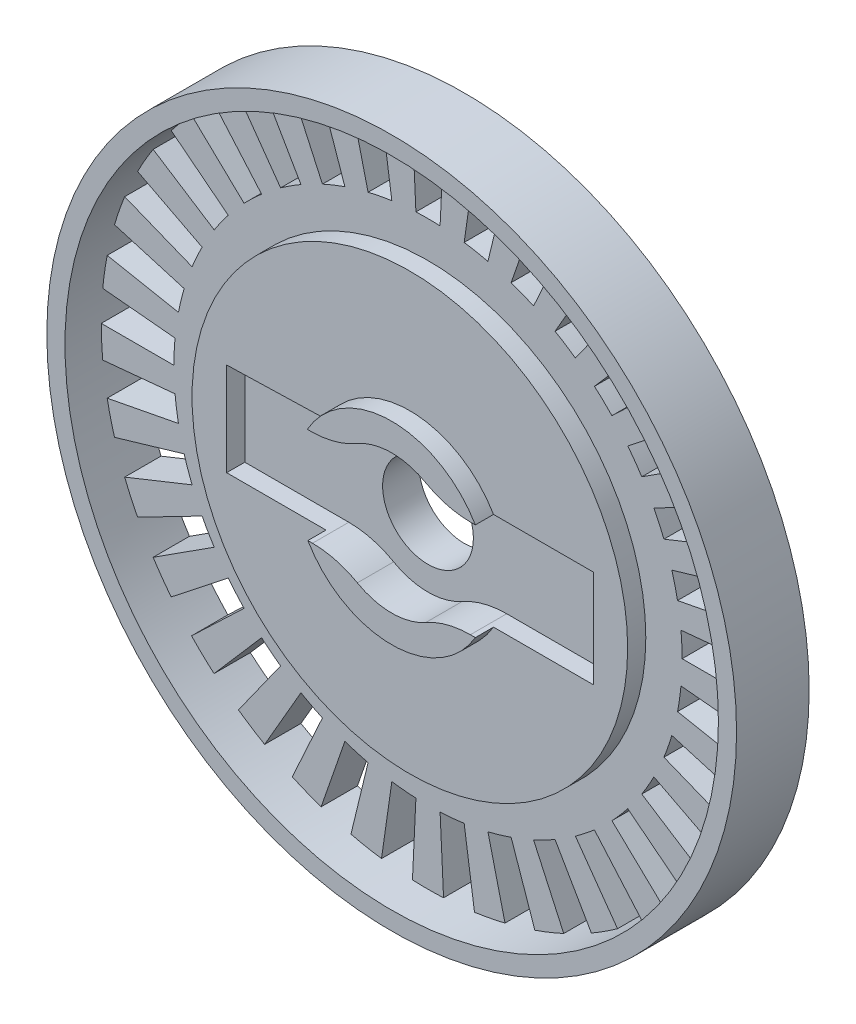
from build123d import *

# Parameters (mm, degrees)
SKETCH1_R           = 20
BOSS_EXTRUDE1_DEPTH = 4
SKETCH2_R           = 2.5
CUT_EXTRUDE1_DEPTH  = 4
CUT_EXTRUDE2_DEPTH  = 2
CUT_EXTRUDE3_DEPTH  = 4
SKETCH5_R           = 18
SKETCH5_R_2         = 12
CUT_EXTRUDE4_DEPTH  = 2
SKETCH6_R           = 13.335707923
SKETCH6_R_2         = 5.335707923
CUT_EXTRUDE5_DEPTH  = 1
FILLET2_R           = 5
SKETCH7_R           = 20
SKETCH7_R_2         = 19
CUT_EXTRUDE6_DEPTH  = 10


with BuildPart() as part:
    # Sketch1 → Boss-Extrude1 (new body)
    with BuildSketch(Plane.XY):
        Circle(SKETCH1_R)
    extrude(amount=BOSS_EXTRUDE1_DEPTH)

    # Sketch2 → Cut-Extrude1 (cut)
    with BuildSketch(Plane.XY.offset(4)):
        Circle(SKETCH2_R)
    extrude(amount=-CUT_EXTRUDE1_DEPTH, mode=Mode.SUBTRACT)

    # Sketch3 → Cut-Extrude2 (cut)
    with BuildSketch(Plane.XY.offset(4)):
        with BuildLine():
            Line((-2.737799224, -2.671157129), (-10.093588243, -2.671157129))
            Line((-10.093588243, -2.671157129), (-10.093588243, 2.468790745))
            Line((-10.093588243, 2.468790745), (-2.739511235, 2.66940128))
            ThreePointArc((-2.739511235, 2.66940128), (-0.013401979, 3.824976521), (2.720738068, 2.688532939))
            Line((2.720738068, 2.688532939), (10.108951703, 2.688532939))
            Line((10.108951703, 2.688532939), (10.108951703, 0.003240604))
            Line((10.108951703, 0.003240604), (10.108951703, -2.686788025))
            Line((10.108951703, -2.686788025), (2.722461223, -2.686788025))
            ThreePointArc((2.722461223, -2.686788025), (-0.010949648, -3.824984327), (-2.737799224, -2.671157129))
        make_face()
    extrude(amount=-CUT_EXTRUDE2_DEPTH, mode=Mode.SUBTRACT)

    # Sketch4 → Cut-Extrude3 (cut)
    with BuildSketch(Plane.XY.offset(4)):
        with BuildLine():
            Line((13.936606916, 1.330784606), (17.918494606, 1.711008779))
            ThreePointArc((17.918494606, 1.711008779), (17.979612105, 0.856474485), (18, 0))
            Line((18, 0), (14, 0))
            ThreePointArc((14, 0), (13.984142749, 0.666146822), (13.936606916, 1.330784606))
        make_face()
        with BuildLine():
            Line((13.936606916, -1.330784606), (17.918494606, -1.711008779))
            ThreePointArc((17.918494606, -1.711008779), (17.816785954, -2.561667089), (17.674716551, -3.406522398))
            Line((17.674716551, -3.406522398), (13.747001762, -2.649517421))
            ThreePointArc((13.747001762, -2.649517421), (13.857500186, -1.992407736), (13.936606916, -1.330784606))
        make_face()
        with BuildLine():
            Line((13.432901631, -3.944255796), (17.270873525, -5.071186023))
            ThreePointArc((17.270873525, -5.071186023), (17.010014737, -5.88722334), (16.710622794, -6.689924202))
            Line((16.710622794, -6.689924202), (12.997151062, -5.203274379))
            ThreePointArc((12.997151062, -5.203274379), (13.230011462, -4.578951486), (13.432901631, -3.944255796))
        make_face()
        with BuildLine():
            Line((12.443696281, -6.415171304), (15.999038076, -8.248077391))
            ThreePointArc((15.999038076, -8.248077391), (15.588457268, -9), (15.142563591, -9.731534714))
            Line((15.142563591, -9.731534714), (11.77754946, -7.568971444))
            ThreePointArc((11.77754946, -7.568971444), (12.124355653, -7), (12.443696281, -6.415171304))
        make_face()
        with BuildLine():
            Line((11.004743326, -8.654225807), (14.148955705, -11.126861752))
            ThreePointArc((14.148955705, -11.126861752), (13.603492338, -11.787493211), (13.027212686, -12.421422207))
            Line((13.027212686, -12.421422207), (10.132276533, -9.661106161))
            ThreePointArc((10.132276533, -9.661106161), (10.580494041, -9.168050275), (11.004743326, -8.654225807))
        make_face()
        with BuildLine():
            Line((9.168050275, -10.580494041), (11.787493211, -13.603492338))
            ThreePointArc((11.787493211, -13.603492338), (11.126861752, -14.148955705), (10.441024372, -14.662367137))
            Line((10.441024372, -14.662367137), (8.120796734, -11.404063329))
            ThreePointArc((8.120796734, -11.404063329), (8.654225807, -11.004743326), (9.168050275, -10.580494041))
        make_face()
        with BuildLine():
            Line((7, -12.124355653), (9, -15.588457268))
            ThreePointArc((9, -15.588457268), (8.248077391, -15.999038076), (7.477470234, -16.373375916))
            Line((7.477470234, -16.373375916), (5.815810182, -12.734847935))
            ThreePointArc((5.815810182, -12.734847935), (6.415171304, -12.443696281), (7, -12.124355653))
        make_face()
        with BuildLine():
            Line((4.578951486, -13.230011462), (5.88722334, -17.010014737))
            ThreePointArc((5.88722334, -17.010014737), (5.071186023, -17.270873525), (4.243660839, -17.49260823))
            Line((4.243660839, -17.49260823), (3.300625097, -13.605361957))
            ThreePointArc((3.300625097, -13.605361957), (3.944255796, -13.432901631), (4.578951486, -13.230011462))
        make_face()
        with BuildLine():
            Line((1.992407736, -13.857500186), (2.561667089, -17.816785954))
            ThreePointArc((2.561667089, -17.816785954), (1.711008779, -17.918494606), (0.856474485, -17.979612105))
            Line((0.856474485, -17.979612105), (0.666146822, -13.984142749))
            ThreePointArc((0.666146822, -13.984142749), (1.330784606, -13.936606916), (1.992407736, -13.857500186))
        make_face()
        with BuildLine():
            Line((-0.666146822, -13.984142749), (-0.856474485, -17.979612105))
            ThreePointArc((-0.856474485, -17.979612105), (-1.711008779, -17.918494606), (-2.561667089, -17.816785954))
            Line((-2.561667089, -17.816785954), (-1.992407736, -13.857500186))
            ThreePointArc((-1.992407736, -13.857500186), (-1.330784606, -13.936606916), (-0.666146822, -13.984142749))
        make_face()
        with BuildLine():
            Line((-3.300625097, -13.605361957), (-4.243660839, -17.49260823))
            ThreePointArc((-4.243660839, -17.49260823), (-5.071186023, -17.270873525), (-5.88722334, -17.010014737))
            Line((-5.88722334, -17.010014737), (-4.578951486, -13.230011462))
            ThreePointArc((-4.578951486, -13.230011462), (-3.944255796, -13.432901631), (-3.300625097, -13.605361957))
        make_face()
        with BuildLine():
            Line((-5.815810182, -12.734847935), (-7.477470234, -16.373375916))
            ThreePointArc((-7.477470234, -16.373375916), (-8.248077391, -15.999038076), (-9, -15.588457268))
            Line((-9, -15.588457268), (-7, -12.124355653))
            ThreePointArc((-7, -12.124355653), (-6.415171304, -12.443696281), (-5.815810182, -12.734847935))
        make_face()
        with BuildLine():
            Line((-8.120796734, -11.404063329), (-10.441024372, -14.662367137))
            ThreePointArc((-10.441024372, -14.662367137), (-11.126861752, -14.148955705), (-11.787493211, -13.603492338))
            Line((-11.787493211, -13.603492338), (-9.168050275, -10.580494041))
            ThreePointArc((-9.168050275, -10.580494041), (-8.654225807, -11.004743326), (-8.120796734, -11.404063329))
        make_face()
        with BuildLine():
            Line((-10.132276533, -9.661106161), (-13.027212686, -12.421422207))
            ThreePointArc((-13.027212686, -12.421422207), (-13.603492338, -11.787493211), (-14.148955705, -11.126861752))
            Line((-14.148955705, -11.126861752), (-11.004743326, -8.654225807))
            ThreePointArc((-11.004743326, -8.654225807), (-10.580494041, -9.168050275), (-10.132276533, -9.661106161))
        make_face()
        with BuildLine():
            Line((-11.77754946, -7.568971444), (-15.142563591, -9.731534714))
            ThreePointArc((-15.142563591, -9.731534714), (-15.588457268, -9), (-15.999038076, -8.248077391))
            Line((-15.999038076, -8.248077391), (-12.443696281, -6.415171304))
            ThreePointArc((-12.443696281, -6.415171304), (-12.124355653, -7), (-11.77754946, -7.568971444))
        make_face()
        with BuildLine():
            Line((-12.997151062, -5.203274379), (-16.710622794, -6.689924202))
            ThreePointArc((-16.710622794, -6.689924202), (-17.010014737, -5.88722334), (-17.270873525, -5.071186023))
            Line((-17.270873525, -5.071186023), (-13.432901631, -3.944255796))
            ThreePointArc((-13.432901631, -3.944255796), (-13.230011462, -4.578951486), (-12.997151062, -5.203274379))
        make_face()
        with BuildLine():
            Line((-13.747001762, -2.649517421), (-17.674716551, -3.406522398))
            ThreePointArc((-17.674716551, -3.406522398), (-17.816785954, -2.561667089), (-17.918494606, -1.711008779))
            Line((-17.918494606, -1.711008779), (-13.936606916, -1.330784606))
            ThreePointArc((-13.936606916, -1.330784606), (-13.857500186, -1.992407736), (-13.747001762, -2.649517421))
        make_face()
        with BuildLine():
            Line((-14, 0), (-18, 0))
            ThreePointArc((-18, 0), (-17.979612105, 0.856474485), (-17.918494606, 1.711008779))
            Line((-17.918494606, 1.711008779), (-13.936606916, 1.330784606))
            ThreePointArc((-13.936606916, 1.330784606), (-13.984142749, 0.666146822), (-14, 0))
        make_face()
        with BuildLine():
            Line((-13.747001762, 2.649517421), (-17.674716551, 3.406522398))
            ThreePointArc((-17.674716551, 3.406522398), (-17.49260823, 4.243660839), (-17.270873525, 5.071186023))
            Line((-17.270873525, 5.071186023), (-13.432901631, 3.944255796))
            ThreePointArc((-13.432901631, 3.944255796), (-13.605361957, 3.300625097), (-13.747001762, 2.649517421))
        make_face()
        with BuildLine():
            Line((-12.997151062, 5.203274379), (-16.710622794, 6.689924202))
            ThreePointArc((-16.710622794, 6.689924202), (-16.373375916, 7.477470234), (-15.999038076, 8.248077391))
            Line((-15.999038076, 8.248077391), (-12.443696281, 6.415171304))
            ThreePointArc((-12.443696281, 6.415171304), (-12.734847935, 5.815810182), (-12.997151062, 5.203274379))
        make_face()
        with BuildLine():
            Line((-11.77754946, 7.568971444), (-15.142563591, 9.731534714))
            ThreePointArc((-15.142563591, 9.731534714), (-14.662367137, 10.441024372), (-14.148955705, 11.126861752))
            Line((-14.148955705, 11.126861752), (-11.004743326, 8.654225807))
            ThreePointArc((-11.004743326, 8.654225807), (-11.404063329, 8.120796734), (-11.77754946, 7.568971444))
        make_face()
        with BuildLine():
            Line((-10.132276533, 9.661106161), (-13.027212686, 12.421422207))
            ThreePointArc((-13.027212686, 12.421422207), (-12.421422207, 13.027212686), (-11.787493211, 13.603492338))
            Line((-11.787493211, 13.603492338), (-9.168050275, 10.580494041))
            ThreePointArc((-9.168050275, 10.580494041), (-9.661106161, 10.132276533), (-10.132276533, 9.661106161))
        make_face()
        with BuildLine():
            Line((-8.120796734, 11.404063329), (-10.441024372, 14.662367137))
            ThreePointArc((-10.441024372, 14.662367137), (-9.731534714, 15.142563591), (-9, 15.588457268))
            Line((-9, 15.588457268), (-7, 12.124355653))
            ThreePointArc((-7, 12.124355653), (-7.568971444, 11.77754946), (-8.120796734, 11.404063329))
        make_face()
        with BuildLine():
            Line((-5.815810182, 12.734847935), (-7.477470234, 16.373375916))
            ThreePointArc((-7.477470234, 16.373375916), (-6.689924202, 16.710622794), (-5.88722334, 17.010014737))
            Line((-5.88722334, 17.010014737), (-4.578951486, 13.230011462))
            ThreePointArc((-4.578951486, 13.230011462), (-5.203274379, 12.997151062), (-5.815810182, 12.734847935))
        make_face()
        with BuildLine():
            Line((-3.300625097, 13.605361957), (-4.243660839, 17.49260823))
            ThreePointArc((-4.243660839, 17.49260823), (-3.406522398, 17.674716551), (-2.561667089, 17.816785954))
            Line((-2.561667089, 17.816785954), (-1.992407736, 13.857500186))
            ThreePointArc((-1.992407736, 13.857500186), (-2.649517421, 13.747001762), (-3.300625097, 13.605361957))
        make_face()
        with BuildLine():
            Line((-0.666146822, 13.984142749), (-0.856474485, 17.979612105))
            ThreePointArc((-0.856474485, 17.979612105), (0, 18), (0.856474485, 17.979612105))
            Line((0.856474485, 17.979612105), (0.666146822, 13.984142749))
            ThreePointArc((0.666146822, 13.984142749), (0, 14), (-0.666146822, 13.984142749))
        make_face()
        with BuildLine():
            Line((1.992407736, 13.857500186), (2.561667089, 17.816785954))
            ThreePointArc((2.561667089, 17.816785954), (3.406522398, 17.674716551), (4.243660839, 17.49260823))
            Line((4.243660839, 17.49260823), (3.300625097, 13.605361957))
            ThreePointArc((3.300625097, 13.605361957), (2.649517421, 13.747001762), (1.992407736, 13.857500186))
        make_face()
        with BuildLine():
            Line((4.578951486, 13.230011462), (5.88722334, 17.010014737))
            ThreePointArc((5.88722334, 17.010014737), (6.689924202, 16.710622794), (7.477470234, 16.373375916))
            Line((7.477470234, 16.373375916), (5.815810182, 12.734847935))
            ThreePointArc((5.815810182, 12.734847935), (5.203274379, 12.997151062), (4.578951486, 13.230011462))
        make_face()
        with BuildLine():
            Line((7, 12.124355653), (9, 15.588457268))
            ThreePointArc((9, 15.588457268), (9.731534714, 15.142563591), (10.441024372, 14.662367137))
            Line((10.441024372, 14.662367137), (8.120796734, 11.404063329))
            ThreePointArc((8.120796734, 11.404063329), (7.568971444, 11.77754946), (7, 12.124355653))
        make_face()
        with BuildLine():
            Line((9.168050275, 10.580494041), (11.787493211, 13.603492338))
            ThreePointArc((11.787493211, 13.603492338), (12.421422207, 13.027212686), (13.027212686, 12.421422207))
            Line((13.027212686, 12.421422207), (10.132276533, 9.661106161))
            ThreePointArc((10.132276533, 9.661106161), (9.661106161, 10.132276533), (9.168050275, 10.580494041))
        make_face()
        with BuildLine():
            Line((11.004743326, 8.654225807), (14.148955705, 11.126861752))
            ThreePointArc((14.148955705, 11.126861752), (14.662367137, 10.441024372), (15.142563591, 9.731534714))
            Line((15.142563591, 9.731534714), (11.77754946, 7.568971444))
            ThreePointArc((11.77754946, 7.568971444), (11.404063329, 8.120796734), (11.004743326, 8.654225807))
        make_face()
        with BuildLine():
            Line((12.443696281, 6.415171304), (15.999038076, 8.248077391))
            ThreePointArc((15.999038076, 8.248077391), (16.373375916, 7.477470234), (16.710622794, 6.689924202))
            Line((16.710622794, 6.689924202), (12.997151062, 5.203274379))
            ThreePointArc((12.997151062, 5.203274379), (12.734847935, 5.815810182), (12.443696281, 6.415171304))
        make_face()
        with BuildLine():
            Line((13.432901631, 3.944255796), (17.270873525, 5.071186023))
            ThreePointArc((17.270873525, 5.071186023), (17.49260823, 4.243660839), (17.674716551, 3.406522398))
            Line((17.674716551, 3.406522398), (13.747001762, 2.649517421))
            ThreePointArc((13.747001762, 2.649517421), (13.605361957, 3.300625097), (13.432901631, 3.944255796))
        make_face()
    extrude(amount=-CUT_EXTRUDE3_DEPTH, mode=Mode.SUBTRACT)

    # Sketch5 → Cut-Extrude4 (cut)
    with BuildSketch(Plane.XY.offset(4)):
        Circle(SKETCH5_R)
        Circle(SKETCH5_R_2, mode=Mode.SUBTRACT)
    extrude(amount=-CUT_EXTRUDE4_DEPTH, mode=Mode.SUBTRACT)

    # Sketch6 → Cut-Extrude5 (cut)
    with BuildSketch(Plane.XY.offset(4)):
        Circle(SKETCH6_R)
        Circle(SKETCH6_R_2, mode=Mode.SUBTRACT)
    extrude(amount=-CUT_EXTRUDE5_DEPTH, mode=Mode.SUBTRACT)

    # Fillet2
    fillet2_edges = [part.edges().sort_by_distance(p)[0] for p in [
        (2.722461223, -2.686788025, 3),
        (-2.737799224, -2.671157129, 3),
        (-2.739511235, 2.66940128, 3),
        (2.720738068, 2.688532939, 3),
    ]]
    fillet(fillet2_edges, radius=FILLET2_R)

    # Sketch7 → Cut-Extrude6 (cut)
    with BuildSketch(Plane(origin=(0, 0, 0), x_dir=(-1, 0, 0), z_dir=(0, 0, -1))):
        Circle(SKETCH7_R)
        Circle(SKETCH7_R_2, mode=Mode.SUBTRACT)
    extrude(amount=-CUT_EXTRUDE6_DEPTH, mode=Mode.SUBTRACT)


solid = part.part
